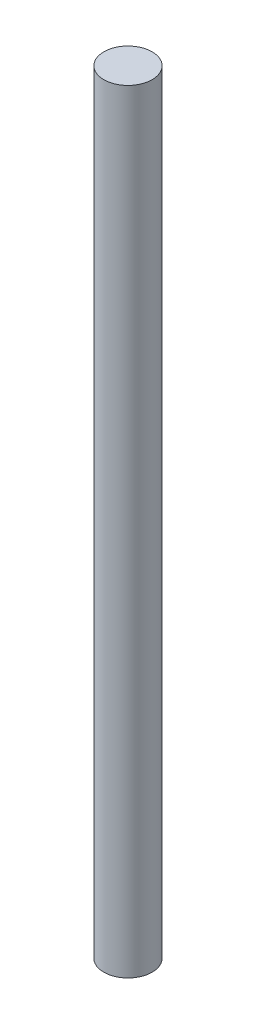
from build123d import *

# Parameters (mm, degrees)
SKETCH1_R           = 3.175
BOSS_EXTRUDE1_DEPTH = 101.6


with BuildPart() as part:
    # Sketch1 → Boss-Extrude1 (new body)
    with BuildSketch(Plane(origin=(0, 0, 0), x_dir=(1, 0, 0), z_dir=(0, 1, 0))):
        Circle(SKETCH1_R)
    extrude(amount=BOSS_EXTRUDE1_DEPTH)


solid = part.part
